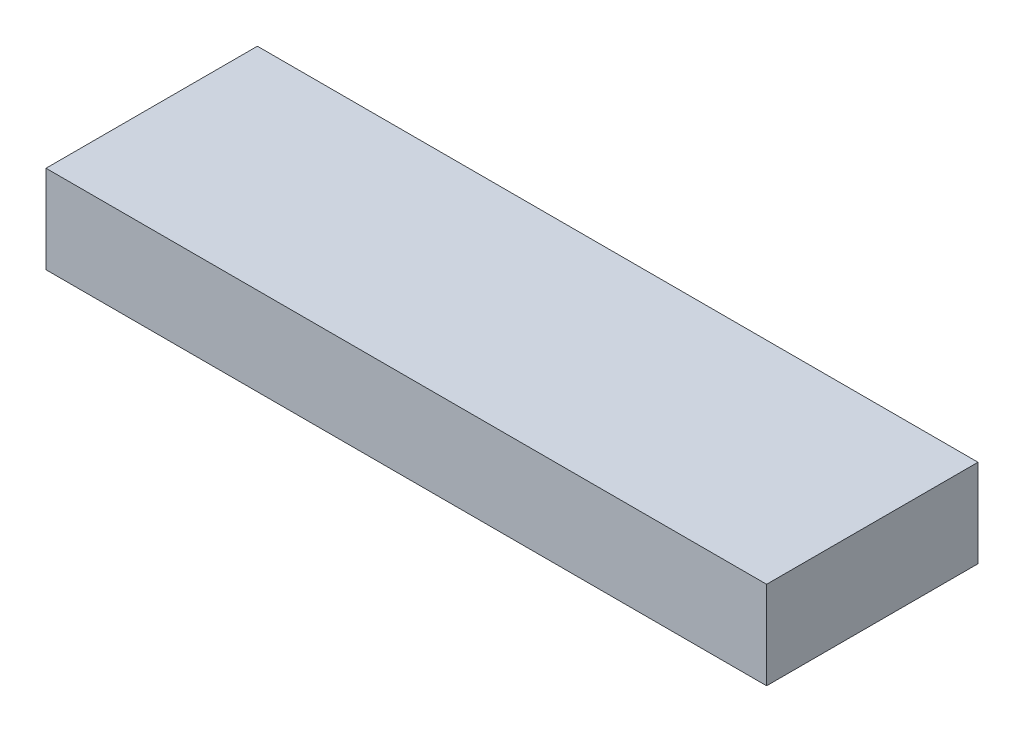
from build123d import *

# Parameters (mm, degrees)
SKETCH1_W           = 2045.299254892
SKETCH1_H           = 249.559060278
BOSS_EXTRUDE1_DEPTH = 600


with BuildPart() as part:
    # Sketch1 → Boss-Extrude1 (new body)
    with BuildSketch(Plane.XY):
        with Locations((8949.141279382, 3332.71259862)):
            Rectangle(SKETCH1_W, SKETCH1_H)
    extrude(amount=BOSS_EXTRUDE1_DEPTH)


solid = part.part
